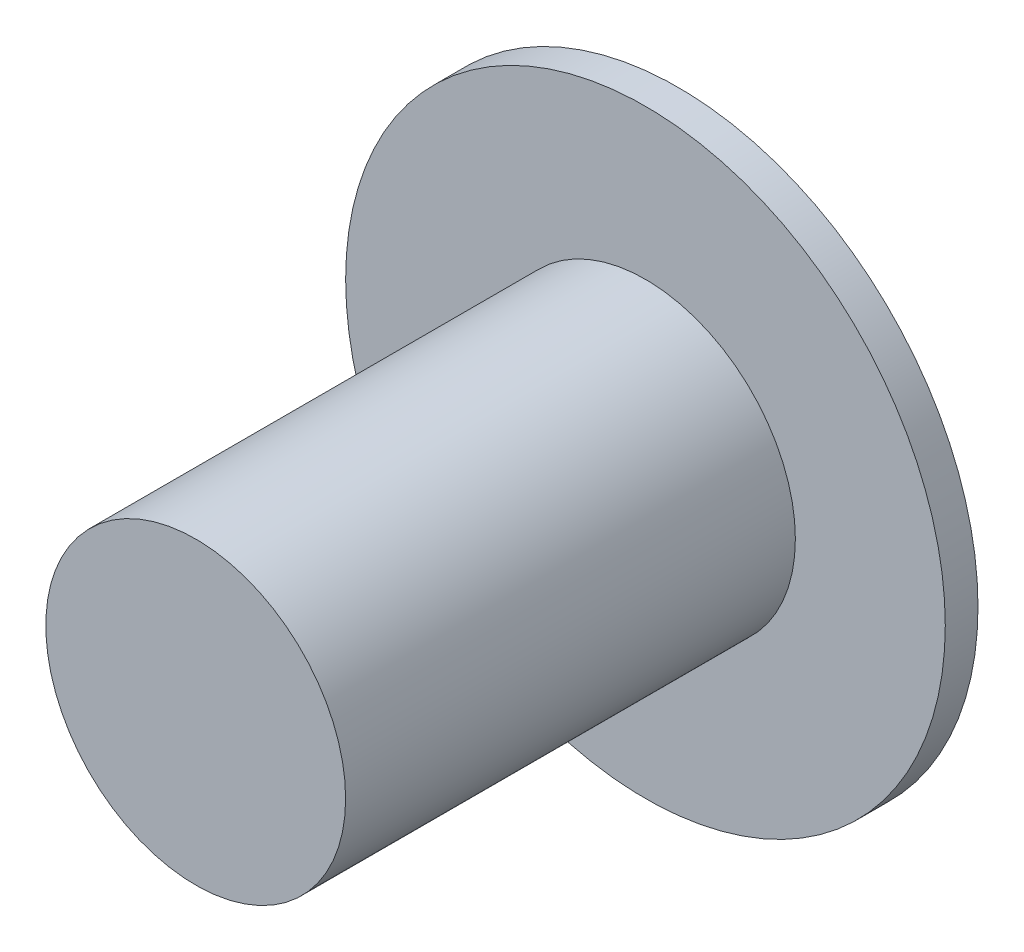
from build123d import *

# Parameters (mm, degrees)
SKETCH1_R           = 11
BOSS_EXTRUDE2_DEPTH = 5
SKETCH3_R           = 22
BOSS_EXTRUDE3_DEPTH = 2.4
SKETCH4_R           = 11
BOSS_EXTRUDE4_DEPTH = 33


with BuildPart() as part:
    # Sketch1 → Boss-Extrude2 (new body)
    with BuildSketch(Plane.XY):
        Circle(SKETCH1_R)
    extrude(amount=BOSS_EXTRUDE2_DEPTH)

    # Sketch3 → Boss-Extrude3 (add)
    with BuildSketch(Plane.XY.offset(5)):
        Circle(SKETCH3_R)
    extrude(amount=BOSS_EXTRUDE3_DEPTH)

    # Sketch4 → Boss-Extrude4 (add)
    with BuildSketch(Plane.XY.offset(7.4)):
        Circle(SKETCH4_R)
    extrude(amount=BOSS_EXTRUDE4_DEPTH)


solid = part.part
